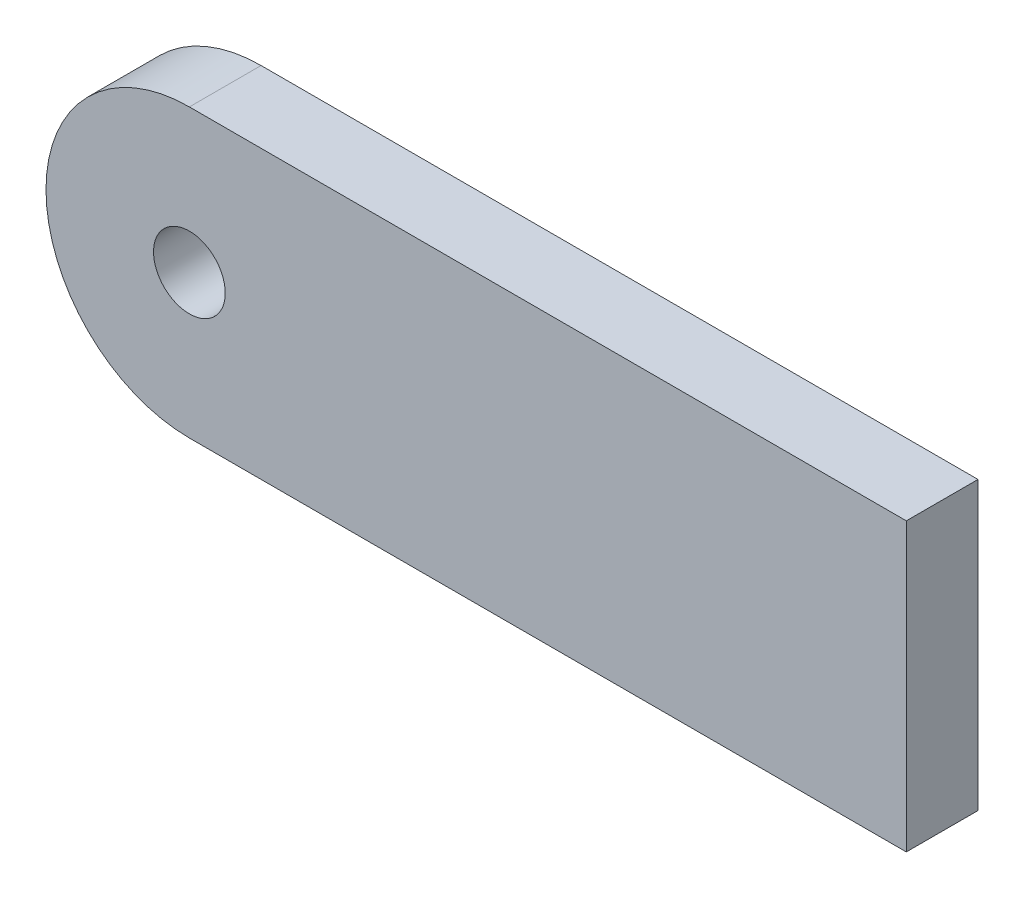
from build123d import *

# Parameters (mm, degrees)
SKETCH1_R           = 1.5875
BOSS_EXTRUDE1_DEPTH = 3.175


with BuildPart() as part:
    # Sketch1 → Boss-Extrude1 (new body)
    with BuildSketch(Plane.XY):
        with BuildLine():
            Line((0, 0), (-31.75, 0))
            ThreePointArc((-31.75, 0), (-38.1, -6.35), (-31.75, -12.7))
            Line((-31.75, -12.7), (0, -12.7))
            Line((0, -12.7), (0, 0))
        make_face()
        with Locations((-31.75, -6.35)):
            Circle(SKETCH1_R, mode=Mode.SUBTRACT)
    extrude(amount=BOSS_EXTRUDE1_DEPTH)


solid = part.part
